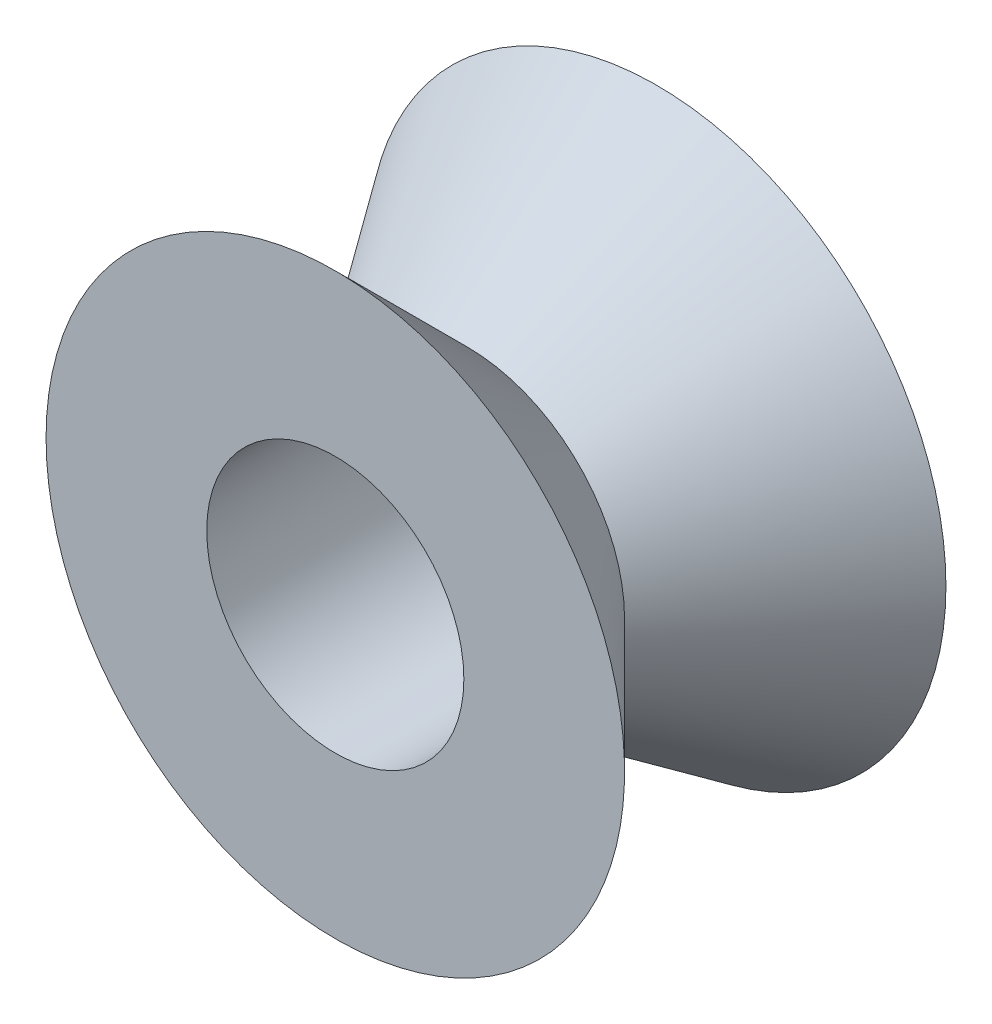
from build123d import *

# Parameters (mm, degrees)
SKETCH1_R           = 9
BOSS_EXTRUDE1_DEPTH = 10
BOSS_EXTRUDE1_TAPER = 35
SKETCH2_R           = 9
BOSS_EXTRUDE2_DEPTH = 10
BOSS_EXTRUDE2_DRAFT = 45
SKETCH3_R           = 4
CUT_EXTRUDE1_DEPTH  = 20


with BuildPart() as part:
    # Sketch1 → Boss-Extrude1 (new body)
    with BuildSketch(Plane.XY):
        Circle(SKETCH1_R)
    extrude(amount=BOSS_EXTRUDE1_DEPTH, taper=BOSS_EXTRUDE1_TAPER)


with BuildPart() as boss_extrude2_tool:
    # Sketch2 → Boss-Extrude2 (with draft: the straight prism first)
    with BuildSketch(Plane(origin=(0, 0, 10), x_dir=(-1, 0, 0), z_dir=(0, 0, -1))):
        Circle(SKETCH2_R)
    extrude(amount=BOSS_EXTRUDE2_DEPTH)
    # Boss-Extrude2: the draft: its side faces are tilted about the plane it starts from
    boss_extrude2_sides = [boss_extrude2_tool.faces().sort_by_distance(p)[0] for p in [
        (9, 0, 5),
    ]]
    draft(boss_extrude2_sides, Plane(origin=(0, 0, 10), x_dir=(-1, 0, 0), z_dir=(0, 0, -1)), BOSS_EXTRUDE2_DRAFT)


with BuildPart() as part_1:
    add(part.part)

    # Boss-Extrude2: add boss_extrude2_tool
    add(boss_extrude2_tool.part)

    # Sketch3 → Cut-Extrude1 (cut)
    with BuildSketch(Plane(origin=(0, 0, 10), x_dir=(-1, 0, 0), z_dir=(0, 0, -1))):
        Circle(SKETCH3_R)
    extrude(amount=CUT_EXTRUDE1_DEPTH, mode=Mode.SUBTRACT)


solid = part_1.part
